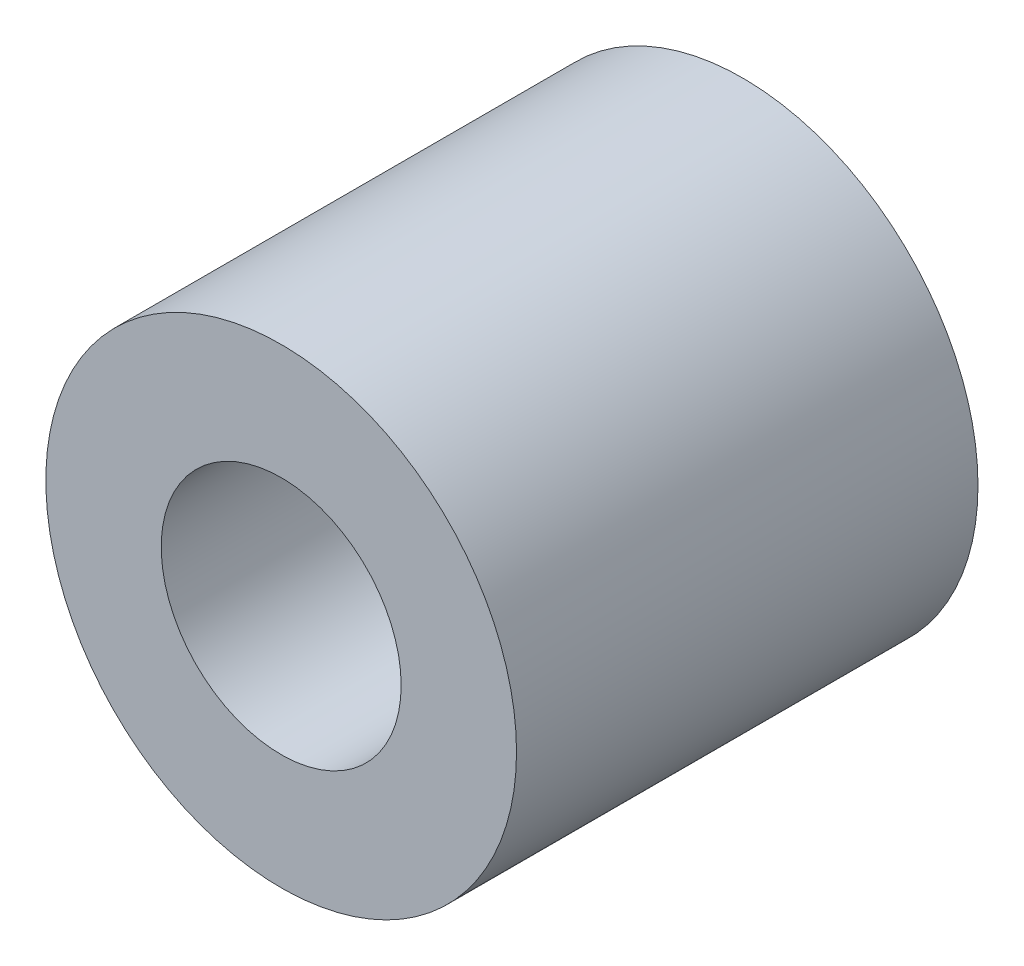
from build123d import *

# Parameters (mm, degrees)
CROQUIS1_R              = 5.1
CROQUIS1_R_2            = 2.6
SALIENTE_EXTRUIR1_DEPTH = 10


with BuildPart() as part:
    # Croquis1 → Saliente-Extruir1 (new body)
    with BuildSketch(Plane.XY):
        Circle(CROQUIS1_R)
        Circle(CROQUIS1_R_2, mode=Mode.SUBTRACT)
    extrude(amount=SALIENTE_EXTRUIR1_DEPTH)


solid = part.part
